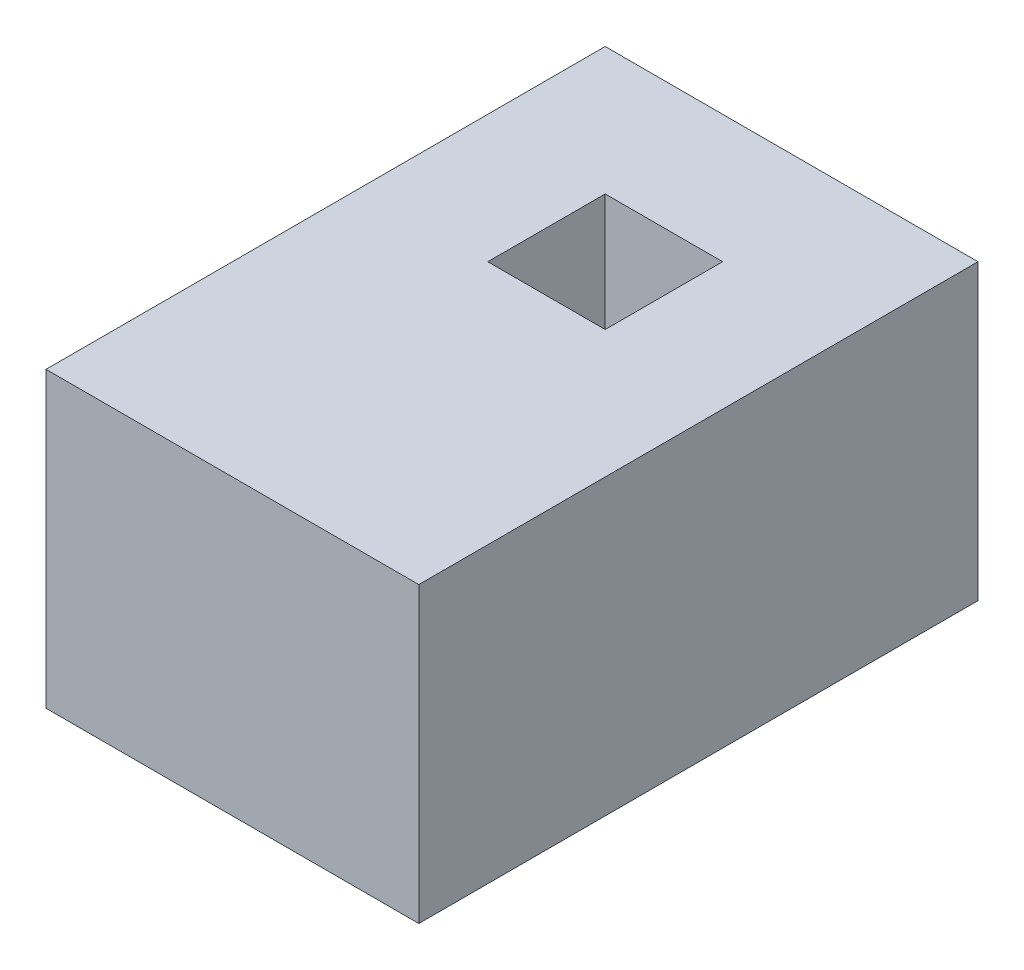
from build123d import *

# Parameters (mm, degrees)
SKETCH1_W           = 1.27
SKETCH1_H           = 1.905
SKETCH1_W_2         = 0.4
SKETCH1_H_2         = 0.4
BOSS_EXTRUDE1_DEPTH = 1


with BuildPart() as part:
    # Sketch1 → Boss-Extrude1 (new body)
    with BuildSketch(Plane(origin=(0, 0, 0), x_dir=(1, 0, 0), z_dir=(0, 1, 0))):
        Rectangle(SKETCH1_W, SKETCH1_H)
        with Locations((0, 0.3175)):
            Rectangle(SKETCH1_W_2, SKETCH1_H_2, mode=Mode.SUBTRACT)
    extrude(amount=BOSS_EXTRUDE1_DEPTH)


solid = part.part
